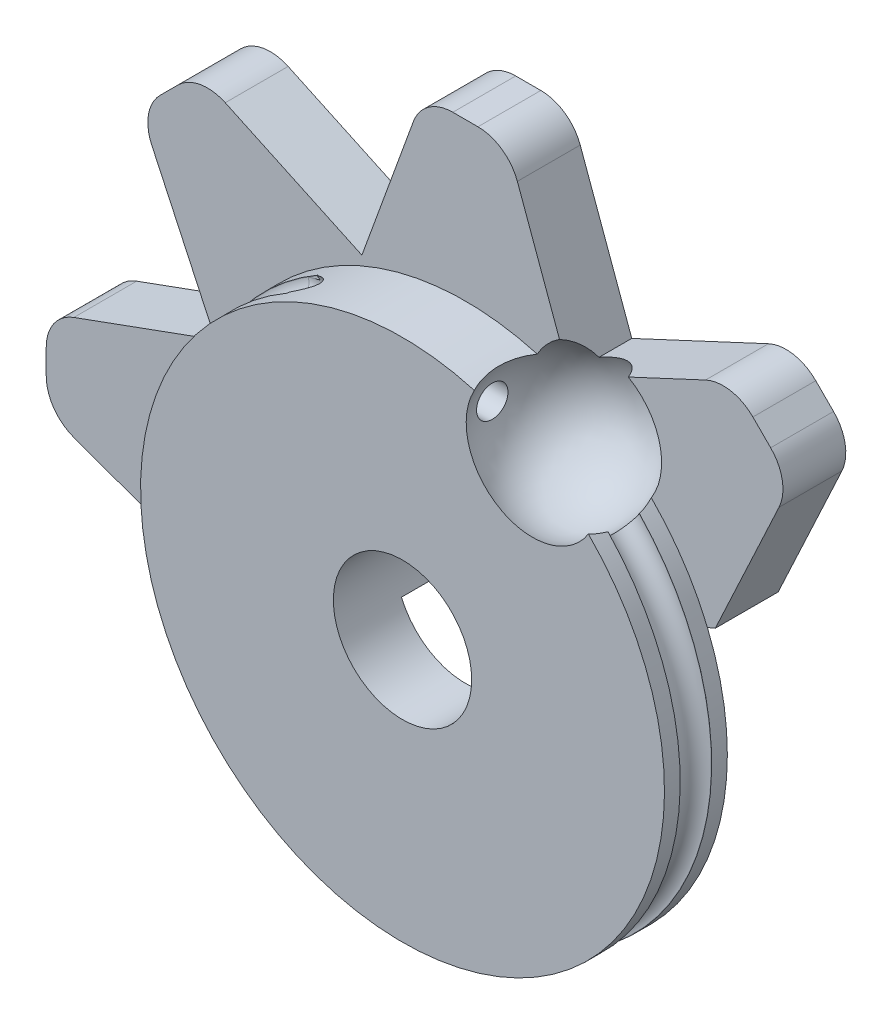
from build123d import *

# Parameters (mm, degrees)
SKETCH1_R                          = 6.25
BODY_DEPTH                         = 1.5
HOLE_TO_TRAP_CABLE_KNOT_DEPTH      = 10
HOLE_TO_TRAP_CABLE_KNOT_DEPTH_BACK = 9.965210539
SKETCH2_R                          = 0.375
THUMB_GRIP_DEPTH                   = 1.5
SKETCH13_R                         = 1.65
HOLE_FOR_SCREW_DEPTH               = 15.456832295


with BuildPart() as part:
    # Sketch1 → body (new body)
    with BuildSketch(Plane.XY):
        Circle(SKETCH1_R)
    extrude(amount=BODY_DEPTH)

    # Sketch2 → Hole to trap cable knot (cut, two sides: drawn at the far end of the back side and taken through both)
    with BuildSketch(Plane(origin=(0, 0, 0), x_dir=(0, 0, -1), z_dir=(1, 0, 0)).offset(-HOLE_TO_TRAP_CABLE_KNOT_DEPTH_BACK)):
        with Locations((-0.75, 5.25)):
            Circle(SKETCH2_R)
        with Locations((-0.75, -4.75)):
            Circle(SKETCH2_R)
    extrude(amount=HOLE_TO_TRAP_CABLE_KNOT_DEPTH + HOLE_TO_TRAP_CABLE_KNOT_DEPTH_BACK, mode=Mode.SUBTRACT)

    # track for cable: sweep along a path in Sketch6
    with BuildLine(Plane.XY.offset(1.875)) as track_for_cable_path:
        ThreePointArc((-3.125, 5.412658774), (-0.078980905, -6.249500941), (3.260789939, 5.331955455))
    # Sketch10 → track for cable (sweep, cut)
    with BuildSketch(Plane(origin=(-5.412658774, 9.375, 0), x_dir=(-0.4999999999999889, 0.866025403784445, 0), z_dir=(-0.866025403784445, -0.4999999999999889, 0))):
        with BuildLine():
            Line((-4.583101682, -1.125), (-3.872701536, -1.125))
            Line((-3.872701536, -1.125), (-3.872701536, -0.374795087))
            Line((-3.872701536, -0.374795087), (-4.583101682, -0.374795087))
            ThreePointArc((-4.583101682, -0.374795087), (-4.958204138, -0.749897543), (-4.583101682, -1.125))
        make_face()
    sweep(path=track_for_cable_path.line, mode=Mode.SUBTRACT)

    # Sketch14 → thumb grip (add)
    with BuildSketch(Plane(origin=(0, 0, 0), x_dir=(-1, 0, 0), z_dir=(0, 0, -1))):
        with BuildLine():
            Line((5.729357486, 7.4822541), (2.469632038, 5.96221916))
            Line((2.469632038, 5.96221916), (1.239485083, 9.342020143))
            ThreePointArc((1.239485083, 9.342020143), (0.873368898, 9.819152044), (0.299792462, 10))
            Line((0.299792462, 10), (-0.299792462, 10))
            ThreePointArc((-0.299792462, 10), (-0.873368898, 9.819152044), (-1.239485083, 9.342020143))
            Line((-1.239485083, 9.342020143), (-2.469632038, 5.96221916))
            Line((-2.469632038, 5.96221916), (-5.729357486, 7.4822541))
            ThreePointArc((-5.729357486, 7.4822541), (-6.325623926, 7.560754066), (-6.859082529, 7.283053095))
            Line((-6.859082529, 7.283053095), (-7.283053095, 6.859082529))
            ThreePointArc((-7.283053095, 6.859082529), (-7.560754066, 6.325623926), (-7.4822541, 5.729357486))
            Line((-7.4822541, 5.729357486), (-5.96221916, 2.469632038))
            Line((-5.96221916, 2.469632038), (5.96221916, -2.469632038))
            Line((5.96221916, -2.469632038), (9.342020143, -1.239485083))
            ThreePointArc((9.342020143, -1.239485083), (9.819152044, -0.873368898), (10, -0.299792462))
            Line((10, -0.299792462), (10, 0.299792462))
            ThreePointArc((10, 0.299792462), (9.819152044, 0.873368898), (9.342020143, 1.239485083))
            Line((9.342020143, 1.239485083), (5.96221916, 2.469632038))
            Line((5.96221916, 2.469632038), (7.4822541, 5.729357486))
            ThreePointArc((7.4822541, 5.729357486), (7.560754066, 6.325623926), (7.283053095, 6.859082529))
            Line((7.283053095, 6.859082529), (6.859082529, 7.283053095))
            ThreePointArc((6.859082529, 7.283053095), (6.325623926, 7.560754066), (5.729357486, 7.4822541))
        make_face()
    extrude(amount=THUMB_GRIP_DEPTH)

    # Sketch13 → hole for screw (cut, through all)
    with BuildSketch(Plane.XY.offset(1.5)):
        Circle(SKETCH13_R)
    extrude(amount=-HOLE_FOR_SCREW_DEPTH, mode=Mode.SUBTRACT)

    # Sketch20 → trap for ball (revolve, cut)
    with BuildSketch(Plane(origin=(3.1, 0, 0), x_dir=(0, 0, -1), z_dir=(1, 0, 0))):
        with BuildLine():
            Line((-0.75, 7), (-0.75, 3.5))
            ThreePointArc((-0.75, 3.5), (1, 5.25), (-0.75, 7))
        make_face()
    revolve(axis=Axis((3.1, 7.793428849, 0.75), (0, -1, 0)), mode=Mode.SUBTRACT)


solid = part.part
